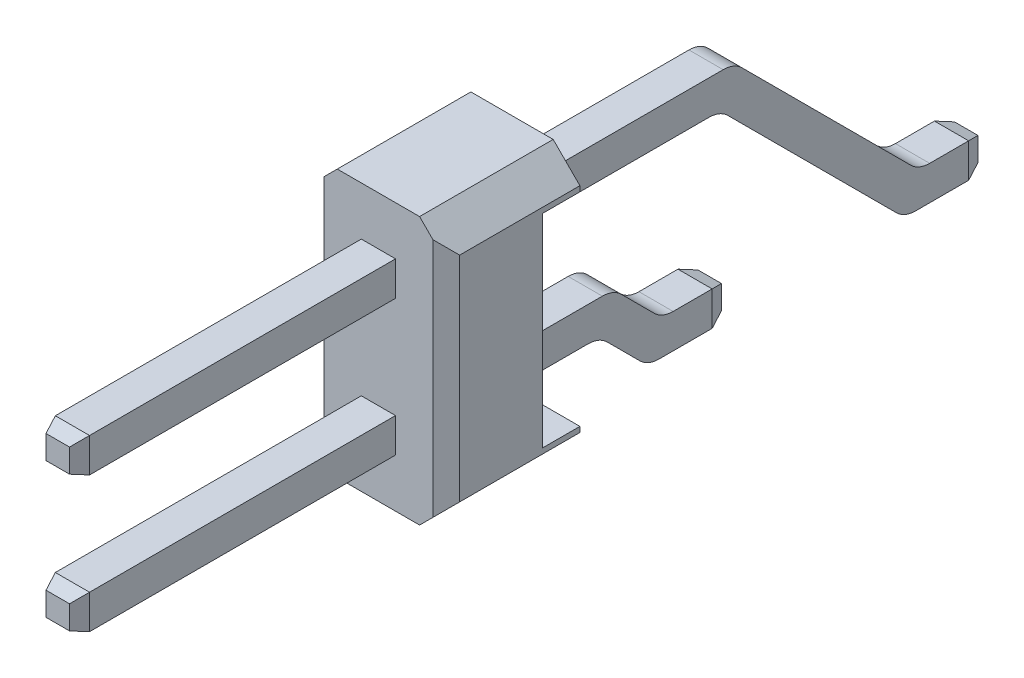
from build123d import *
from OCP.BRepFilletAPI import BRepFilletAPI_MakeChamfer

# Parameters (mm, degrees)
EXTRUDE_1_DEPTH   = 0.32
EXTRUDE_1_2_DEPTH = 0.32
CHAMFER_1_SIZE    = 0.1
CHAMFER_1_SIZE2   = 0.274747742
FILLET_1_R        = 0.5
CHAMFER_2_SIZE    = 0.1
CHAMFER_2_SIZE2   = 0.274747742
FILLET_2_R        = 0.5
SKETCH_2_W        = 2.54
SKETCH_2_H        = 5
EXTRUDE_2_DEPTH   = 1.8
CHAMFER_3_SIZE    = 0.5
CHAMFER_4_SIZE    = 0.25
EXTRUDE_3_DEPTH   = 0.7


with BuildPart() as part:
    # Эскиз1 → Бобышка-Вытянуть1 (new, symmetric)
    with BuildSketch(Plane(origin=(0, 0, 0), x_dir=(0, 0, -1), z_dir=(1, 0, 0))):
        Polygon((-0.7385, 0), (0.7385, 0), (0.7385, 0.64), (-0.47340332, 0.64), (-1.38340332, 1.55), (-11.4615, 1.55), (-11.4615, 0.91), (-1.6485, 0.91), align=None)
    extrude(amount=EXTRUDE_1_DEPTH, both=True)

    # Фаска2: one chamfer whose edges measure the first distance from different faces: ONE call of the kernel's chamfer builder (chamfer() names one face for all edges)
    chamfer_2_edges_1 = [part.edges().sort_by_distance(p)[0] for p in [
        (0.32, 0.32, -0.7385),
        (0, 0, -0.7385),
        (0, 0.64, -0.7385),
        (-0.32, 0.32, -0.7385),
    ]]
    chamfer_2_side_1 = [part.faces().sort_by_distance(p)[0] for p in [
        (0, 0.32, -0.7385),
    ]]
    chamfer_2_edges_2 = [part.edges().sort_by_distance(p)[0] for p in [
        (0, 0.91, 11.4615),
        (0, 1.55, 11.4615),
        (-0.32, 1.23, 11.4615),
        (0.32, 1.23, 11.4615),
    ]]
    chamfer_2_side_2 = [part.faces().sort_by_distance(p)[0] for p in [
        (0, 1.23, 11.4615),
    ]]
    chamfer_2 = BRepFilletAPI_MakeChamfer(part.part.solid().wrapped)
    for e in chamfer_2_edges_1:
        chamfer_2.Add(CHAMFER_2_SIZE, CHAMFER_2_SIZE2, e.wrapped, chamfer_2_side_1[0].wrapped)  # the first distance lies on this face
    for e in chamfer_2_edges_2:
        chamfer_2.Add(CHAMFER_2_SIZE, CHAMFER_2_SIZE2, e.wrapped, chamfer_2_side_2[0].wrapped)  # the first distance lies on this face
    add(Compound.cast(chamfer_2.Shape()), mode=Mode.REPLACE)

    # Скругление2
    fillet_2_edges = [part.edges().sort_by_distance(p)[0] for p in [
        (0, 0, 0.7385),
        (0, 0.91, 1.6485),
        (0, 1.55, 1.38340332),
        (0, 0.64, 0.47340332),
    ]]
    fillet(fillet_2_edges, radius=FILLET_2_R)



with BuildPart() as body_2:
    # Эскиз1 → Extrude 1 2 (new, symmetric)
    with BuildSketch(Plane(origin=(0, 0, 0), x_dir=(0, 0, -1), z_dir=(1, 0, 0))):
        Polygon((4.0615, 0), (5.5385, 0), (5.5385, 0.64), (4.32659668, 0.64), (0.87659668, 4.09), (-11.4615, 4.09), (-11.4615, 3.45), (0.6115, 3.45), align=None)
    extrude(amount=EXTRUDE_1_2_DEPTH, both=True)

    # Фаска1: one chamfer whose edges measure the first distance from different faces: ONE call of the kernel's chamfer builder (chamfer() names one face for all edges)
    chamfer_1_edges_1 = [body_2.edges().sort_by_distance(p)[0] for p in [
        (-0.32, 0.32, -5.5385),
        (0, 0.64, -5.5385),
        (0, 0, -5.5385),
        (0.32, 0.32, -5.5385),
    ]]
    chamfer_1_side_1 = [body_2.faces().sort_by_distance(p)[0] for p in [
        (0, 0.32, -5.5385),
    ]]
    chamfer_1_edges_2 = [body_2.edges().sort_by_distance(p)[0] for p in [
        (0, 3.45, 11.4615),
        (0, 4.09, 11.4615),
        (-0.32, 3.77, 11.4615),
        (0.32, 3.77, 11.4615),
    ]]
    chamfer_1_side_2 = [body_2.faces().sort_by_distance(p)[0] for p in [
        (0, 3.77, 11.4615),
    ]]
    chamfer_1 = BRepFilletAPI_MakeChamfer(body_2.part.solid().wrapped)
    for e in chamfer_1_edges_1:
        chamfer_1.Add(CHAMFER_1_SIZE, CHAMFER_1_SIZE2, e.wrapped, chamfer_1_side_1[0].wrapped)  # the first distance lies on this face
    for e in chamfer_1_edges_2:
        chamfer_1.Add(CHAMFER_1_SIZE, CHAMFER_1_SIZE2, e.wrapped, chamfer_1_side_2[0].wrapped)  # the first distance lies on this face
    add(Compound.cast(chamfer_1.Shape()), mode=Mode.REPLACE)

    # Скругление1
    fillet_1_edges = [body_2.edges().sort_by_distance(p)[0] for p in [
        (0, 3.45, -0.6115),
        (0, 4.09, -0.87659668),
        (0, 0.64, -4.32659668),
        (0, 0, -4.0615),
    ]]
    fillet(fillet_1_edges, radius=FILLET_1_R)


with BuildPart() as part_1:
    add(part.part)

    add(body_2.part)  # Бобышка-Вытянуть2 merges body 2
    # Эскиз2 → Бобышка-Вытянуть2 (add)
    with BuildSketch(Plane.XY.offset(3.661)):
        with Locations((0, 2.5)):
            Rectangle(SKETCH_2_W, SKETCH_2_H)
    extrude(amount=EXTRUDE_2_DEPTH)

    # Фаска3
    chamfer_3_edges = [part_1.edges().sort_by_distance(p)[0] for p in [
        (1.27, 0, 4.561),
        (1.27, 5, 4.561),
        (-1.27, 5, 4.561),
        (-1.27, 0, 4.561),
    ]]
    chamfer(chamfer_3_edges, length=CHAMFER_3_SIZE)

    # Фаска4
    chamfer_4_edges = [part_1.edges().sort_by_distance(p)[0] for p in [
        (-1.27, 2.5, 5.461),
        (1.27, 2.5, 5.461),
    ]]
    chamfer(chamfer_4_edges, length=CHAMFER_4_SIZE)

    # Эскиз3 → Бобышка-Вытянуть3 (add)
    with BuildSketch(Plane(origin=(0, 0, 3.661), x_dir=(-1, 0, 0), z_dir=(0, 0, -1))):
        Polygon((-1.27, 4.5), (-0.77, 5), (0.77, 5), (1.27, 4.5), (1.27, 4.4), (-1.27, 4.4), align=None)
        Polygon((-1.27, 0.6), (-1.27, 0.5), (-0.77, 0), (0.77, 0), (1.27, 0.5), (1.27, 0.6), align=None)
    extrude(amount=EXTRUDE_3_DEPTH)


solid = part_1.part
